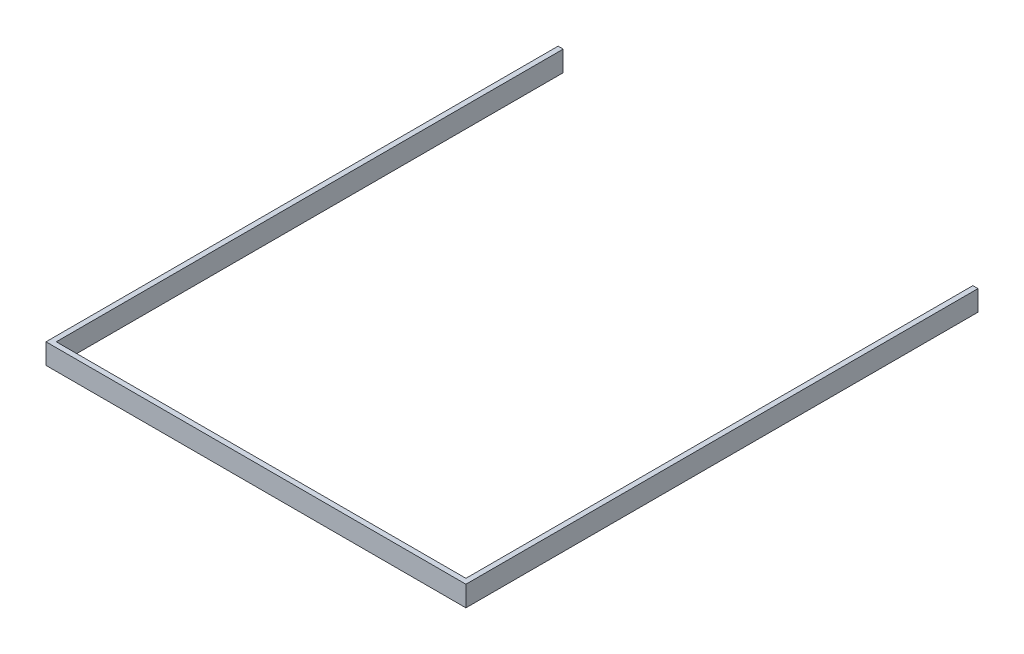
from build123d import *

# Parameters (mm, degrees)
ESQUISSE1_W             = 164
ESQUISSE1_H             = 8
BOSS_EXTRU_1_DEPTH      = 200
ESQUISSE2_W             = 160
ESQUISSE2_H             = 8
ENL_V_MAT_EXTRU_2_DEPTH = 198


with BuildPart() as part:
    # Esquisse1 → Boss.-Extru.1 (new body)
    with BuildSketch(Plane.XY):
        with Locations((82, -4)):
            Rectangle(ESQUISSE1_W, ESQUISSE1_H)
    extrude(amount=BOSS_EXTRU_1_DEPTH)

    # Esquisse2 → Enlèv. mat.-Extru.2 (cut)
    with BuildSketch(Plane.XY):
        with Locations((82, -4)):
            Rectangle(ESQUISSE2_W, ESQUISSE2_H)
    extrude(amount=ENL_V_MAT_EXTRU_2_DEPTH, mode=Mode.SUBTRACT)


solid = part.part
